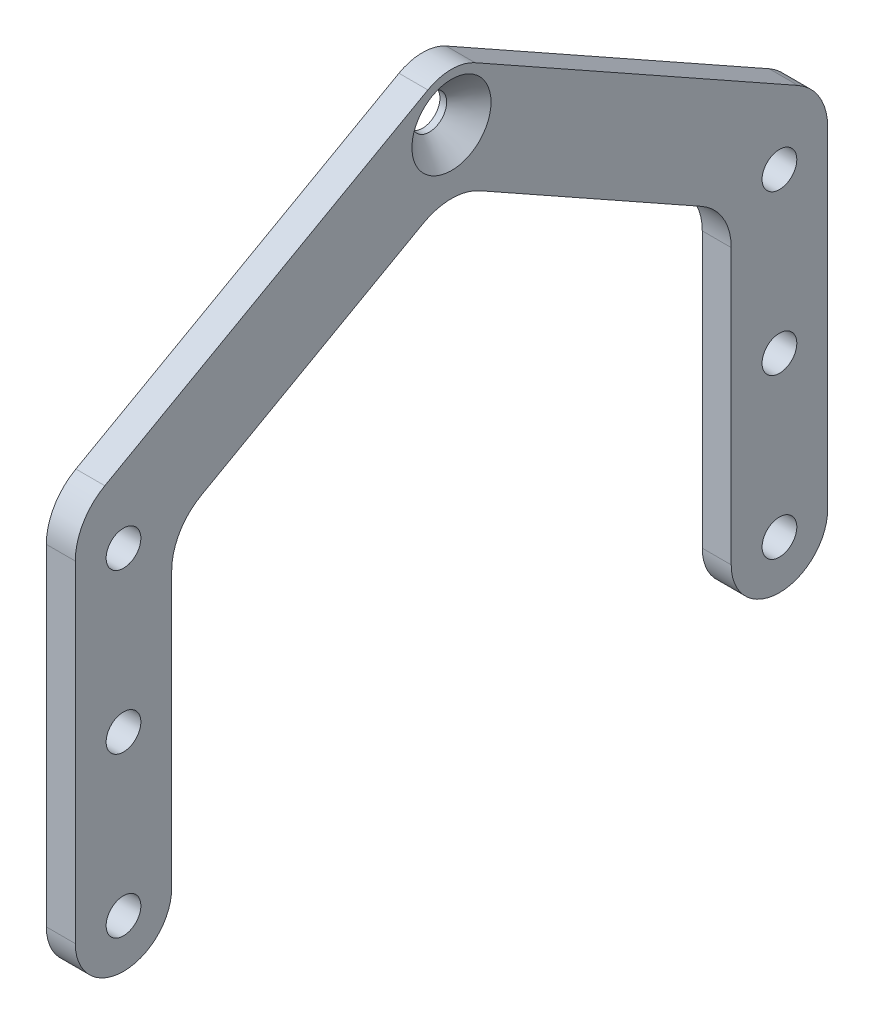
from build123d import *

# Parameters (mm, degrees)
SKETCH_1_R          = 0.9
EXTRUDE_1_DEPTH     = 1.5
FILLET_1_R          = 3
SKETCH_2_R          = 0.9
CUT_EXTRUDE_1_DEPTH = 10


with BuildPart() as part:
    # 草图1 → 凸台-拉伸1 (new body)
    with BuildSketch(Plane(origin=(0, 0, 0), x_dir=(0, 0, -1), z_dir=(1, 0, 0))):
        with BuildLine():
            Line((-14.5, 0), (-14.5, 16))
            Line((-14.5, 16), (0, 24.133548193))
            Line((0, 24.133548193), (14.5, 16))
            Line((14.5, 16), (14.5, 0))
            ThreePointArc((14.5, 0), (17, -2.5), (19.5, 0))
            Line((19.5, 0), (19.5, 18.928231824))
            Line((19.5, 18.928231824), (1.22305902, 29.180395981))
            ThreePointArc((1.22305902, 29.180395981), (0, 29.5), (-1.22305902, 29.180395981))
            Line((-1.22305902, 29.180395981), (-19.5, 18.928231824))
            Line((-19.5, 18.928231824), (-19.5, 0))
            ThreePointArc((-19.5, 0), (-17, -2.5), (-14.5, 0))
        make_face()
        with Locations((-17, 0)):
            Circle(SKETCH_1_R, mode=Mode.SUBTRACT)
        with Locations(Location((17, 0, 0), (0, 0, 180))):  # turned: the seam where the file's is
            Circle(SKETCH_1_R, mode=Mode.SUBTRACT)
        with Locations((0, 27)):
            Circle(SKETCH_1_R, mode=Mode.SUBTRACT)
    extrude(amount=EXTRUDE_1_DEPTH)

    # 圆角1
    fillet_1_edges = [part.edges().sort_by_distance(p)[0] for p in [
        (0.75, 18.928231824, 19.5),
        (0.75, 18.928231824, -19.5),
        (0.75, 16, -14.5),
        (0.75, 24.133548193, 0),
        (0.75, 16, 14.5),
    ]]
    fillet(fillet_1_edges, radius=FILLET_1_R)

    # 草图2 → 切除-拉伸1 (cut)
    with BuildSketch(Plane(origin=(1.5, 0, 0), x_dir=(0, 0, -1), z_dir=(1, 0, 0))):
        with Locations((-17, 16.5)):
            Circle(SKETCH_2_R)
        with Locations((-17, 8.25)):
            Circle(SKETCH_2_R)
        with Locations((17, 8.25)):
            Circle(SKETCH_2_R)
        with Locations((17, 16.5)):
            Circle(SKETCH_2_R)
    extrude(amount=-CUT_EXTRUDE_1_DEPTH, mode=Mode.SUBTRACT)

    # 草图3 → M2 平头机械螺钉的锥形沉头孔1 (revolve, cut)
    with BuildSketch(Plane(origin=(1.5, 27, 0), x_dir=(0, 0, -1), z_dir=(0, 1, 0))):
        Polygon((0, 0), (0, 1.5), (0.85, 1.5), (0.85, 1.2), (2.05, 0), align=None)
    revolve(axis=Axis((7.85, 27, 0), (-1, 0, 0)), mode=Mode.SUBTRACT)


solid = part.part
